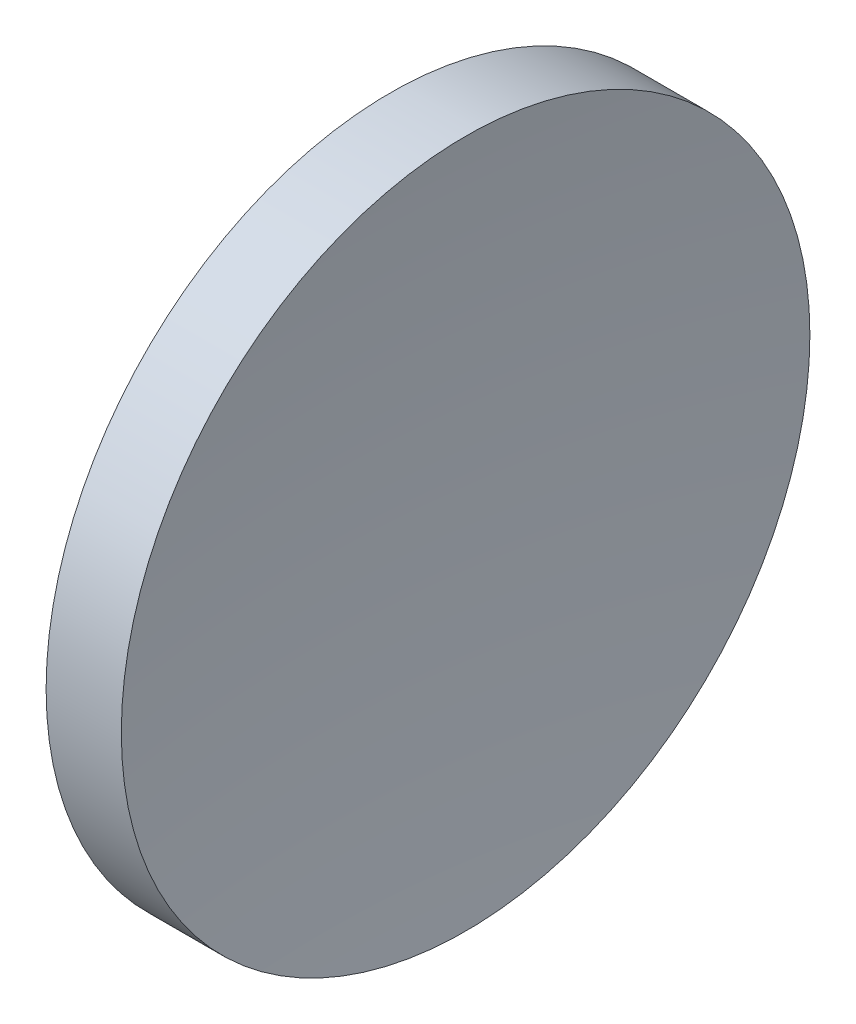
from build123d import *


with BuildPart() as part:
    # 草图1 → 旋转1 (revolve)
    with BuildSketch(Plane.XY, mode=Mode.PRIVATE) as revolve_1_sk:
        with BuildLine():
            Line((119.506834179, 71.193989087), (119.506834179, 83.893989087))
            Line((119.506834179, 83.893989087), (122.281079382, 83.893989087))
            ThreePointArc((122.281079382, 83.893989087), (121.701778246, 77.555705095), (121.506834179, 71.193989087))
            Line((121.506834179, 71.193989087), (119.506834179, 71.193989087))
        make_face()
    revolve(revolve_1_sk.sketch.rotate(Axis((111.955229758, 71.193989087, 0), (1, 0, 0)), 90), axis=Axis((111.955229758, 71.193989087, 0), (1, 0, 0)))  # turned: the seam where the file's is


solid = part.part
